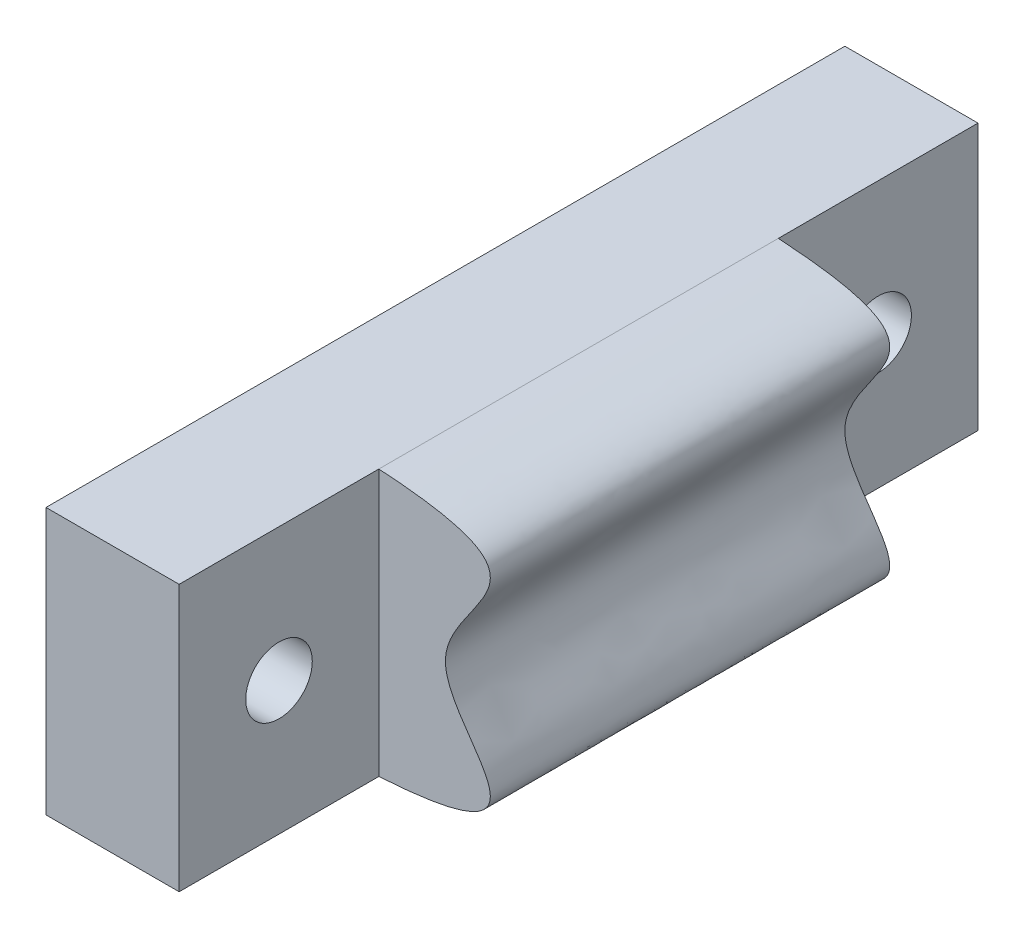
from build123d import *

# Parameters (mm, degrees)
BOSS_EXTRUDE1_DEPTH = 76.2
CUT_EXTRUDE1_DEPTH  = 19.05
CUT_EXTRUDE2_DEPTH  = 19.05
SKETCH4_R           = 3.175
CUT_EXTRUDE3_DEPTH  = 13.7


with BuildPart() as part:
    # Sketch1 → Boss-Extrude1 (new body)
    with BuildSketch(Plane.XY):
        with BuildLine():
            Line((-6.35, -12.7), (6.35, -12.7))
            add(Edge.make_bspline(
                [(6.35, 12.7), (25.715251748, 11.504486328), (-0.315251748, 0), (25.715251748, -11.504486328), (6.35, -12.7)],
                knots=[0, 0, 0, 0, 0.5, 1, 1, 1, 1], degree=3))
            Line((6.35, 12.7), (-6.35, 12.7))
            Line((-6.35, 12.7), (-6.35, -12.7))
        make_face()
    extrude(amount=BOSS_EXTRUDE1_DEPTH)

    # Sketch2 → Cut-Extrude1 (cut)
    with BuildSketch(Plane.XY.offset(76.2)):
        with BuildLine():
            Line((6.35, 12.7), (6.35, -12.7))
            add(Edge.make_bspline(
                [(6.35, -12.7), (25.715251748, -11.504486328), (-0.315251748, 0), (25.715251748, 11.504486328), (6.35, 12.7)],
                knots=[0, 0, 0, 0, 0.5, 1, 1, 1, 1], degree=3))
        make_face()
    extrude(amount=-CUT_EXTRUDE1_DEPTH, mode=Mode.SUBTRACT)

    # Sketch3 → Cut-Extrude2 (cut)
    with BuildSketch(Plane(origin=(0, 0, 0), x_dir=(-1, 0, 0), z_dir=(0, 0, -1))):
        with BuildLine():
            Line((-6.35, 12.7), (-6.35, -12.7))
            add(Edge.make_bspline(
                [(-6.35, -12.7), (-25.715251748, -11.504486328), (0.315251748, 0), (-25.715251748, 11.504486328), (-6.35, 12.7)],
                knots=[0, 0, 0, 0, 0.5, 1, 1, 1, 1], degree=3))
        make_face()
    extrude(amount=-CUT_EXTRUDE2_DEPTH, mode=Mode.SUBTRACT)

    # Sketch4 → Cut-Extrude3 (cut, through all)
    with BuildSketch(Plane(origin=(6.35, 0, 0), x_dir=(0, 0, -1), z_dir=(1, 0, 0))):
        with Locations((-66.675, 0)):
            Circle(SKETCH4_R)
        with Locations((-9.525, 0)):
            Circle(SKETCH4_R)
    extrude(amount=-CUT_EXTRUDE3_DEPTH, mode=Mode.SUBTRACT)


solid = part.part
